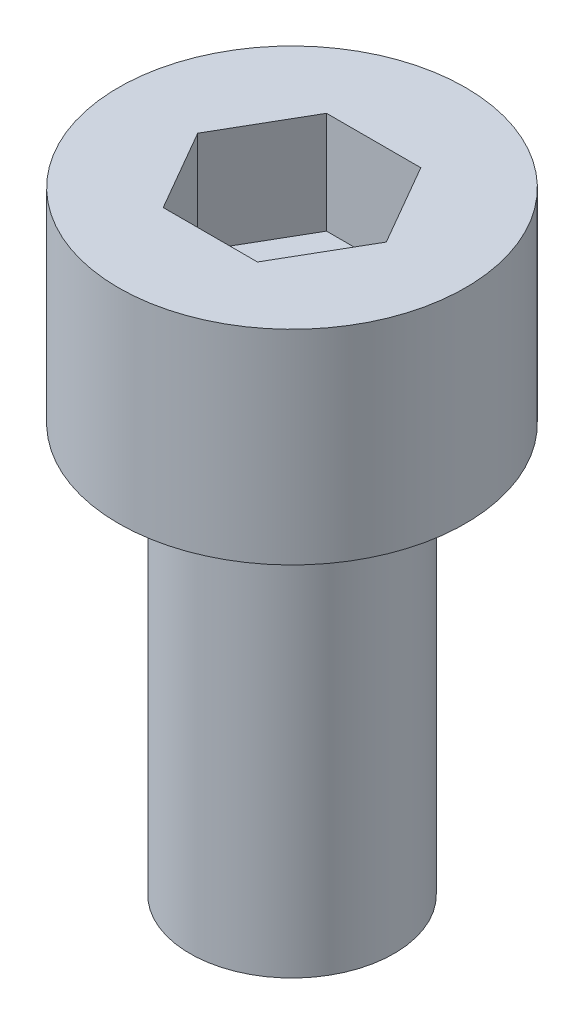
from build123d import *

# Parameters (mm, degrees)
SKETCH_1_R          = 4.25
EXTRUDE_1_DEPTH     = 5
CUT_EXTRUDE_1_DEPTH = 2.5
SKETCH_3_R          = 2.5
EXTRUDE_2_DEPTH     = 10


with BuildPart() as part:
    # 草图1 → 凸台-拉伸1 (new body)
    with BuildSketch(Plane(origin=(0, 0, 0), x_dir=(1, 0, 0), z_dir=(0, 1, 0))):
        Circle(SKETCH_1_R)
    extrude(amount=EXTRUDE_1_DEPTH)

    # 草图2 → 切除-拉伸1 (cut)
    with BuildSketch(Plane(origin=(0, 5, 0), x_dir=(1, 0, 0), z_dir=(0, 1, 0))):
        Polygon((2.309401077, 0), (1.154700538, 2), (-1.154700538, 2), (-2.309401077, 0), (-1.154700538, -2), (1.154700538, -2), align=None)
    extrude(amount=-CUT_EXTRUDE_1_DEPTH, mode=Mode.SUBTRACT)

    # 草图3 → 凸台-拉伸2 (add)
    with BuildSketch(Plane.XZ):
        Circle(SKETCH_3_R)
    extrude(amount=EXTRUDE_2_DEPTH)


solid = part.part
